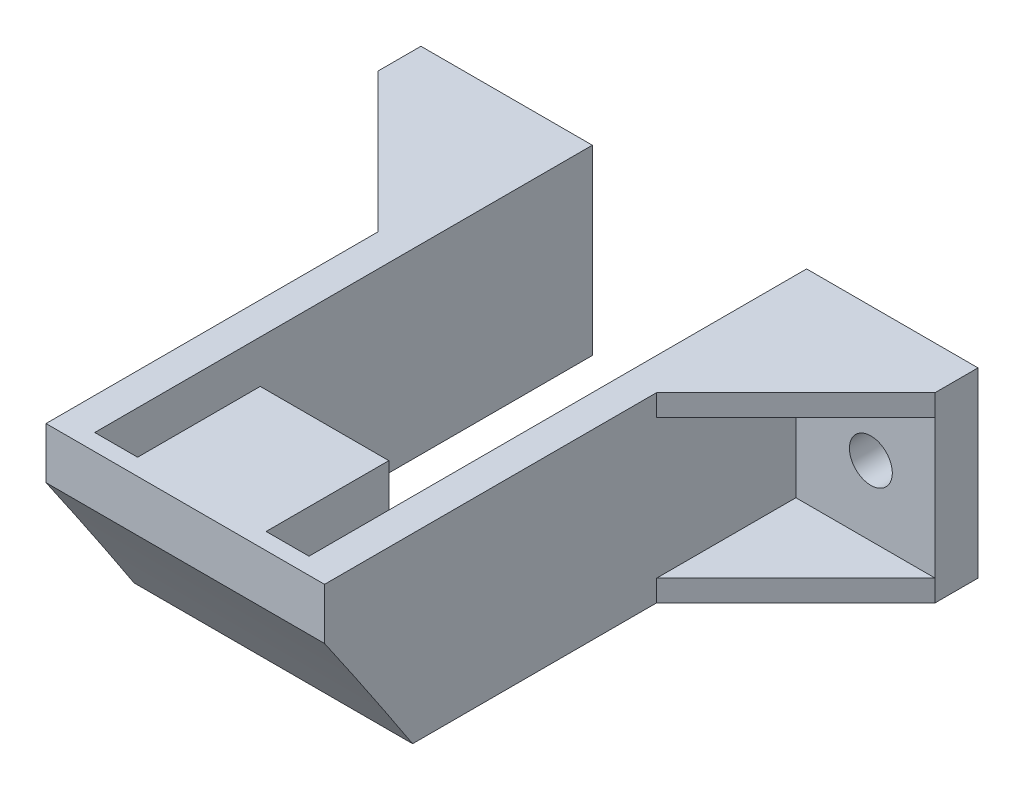
from build123d import *

# Parameters (mm, degrees)
BOSS_EXTRUDE1_DEPTH = 17
BOSS_EXTRUDE2_DEPTH = 2
BOSS_EXTRUDE3_DEPTH = 2
SKETCH6_R           = 2
CUT_EXTRUDE1_DEPTH  = 10
CUT_EXTRUDE2_DEPTH  = 4
CUT_EXTRUDE3_DEPTH  = 100
CUT_EXTRUDE4_DEPTH  = 4


with BuildPart() as part:
    # Sketch1 → Boss-Extrude1 (new body)
    with BuildSketch(Plane(origin=(0, 0, 0), x_dir=(1, 0, 0), z_dir=(0, 1, 0))):
        Polygon((-7.978390595, -3.663628582), (12.021609405, -3.663628582), (12.021609405, 31.336371418), (28.021609405, 31.336371418), (28.021609405, 27.336371418), (15.021609405, 27.336371418), (15.021609405, 18.231970095), (15.021609405, -16.663628582), (-10.978390595, -16.663628582), (-10.978390595, 22.152823879), (-10.978390595, 27.336371418), (-23.978390595, 27.336371418), (-23.978390595, 31.336371418), (-7.978390595, 31.336371418), align=None)
    extrude(amount=BOSS_EXTRUDE1_DEPTH)

    # Sketch4 → Boss-Extrude2 (add)
    with BuildSketch(Plane(origin=(0, 17, 0), x_dir=(1, 0, 0), z_dir=(0, 1, 0))):
        Polygon((-23.978390595, 27.336371418), (-10.978390595, 14.336371418), (-10.978390595, 27.336371418), align=None)
        Polygon((28.021609405, 27.336371418), (15.021609405, 14.336371418), (15.021609405, 27.336371418), align=None)
    extrude(amount=-BOSS_EXTRUDE2_DEPTH)

    # Sketch5 → Boss-Extrude3 (add)
    with BuildSketch(Plane.XZ):
        Polygon((-23.978390595, -27.336371418), (-10.978390595, -14.336371418), (-10.978390595, -27.336371418), align=None)
        Polygon((15.021609405, -14.336371418), (28.021609405, -27.336371418), (15.021609405, -27.336371418), align=None)
    extrude(amount=-BOSS_EXTRUDE3_DEPTH)

    # Sketch6 → Cut-Extrude1 (cut)
    with BuildSketch(Plane(origin=(0, 0, -31.336371418), x_dir=(-1, 0, 0), z_dir=(0, 0, -1))):
        with Locations((-22.021609405, 8.5)):
            Circle(SKETCH6_R)
        with Locations((17.978390595, 8.5)):
            Circle(SKETCH6_R)
    extrude(amount=-CUT_EXTRUDE1_DEPTH, mode=Mode.SUBTRACT)

    # Sketch7 → Cut-Extrude2 (cut)
    with BuildSketch(Plane(origin=(-7.978390595, 0, 0), x_dir=(0, 0, -1), z_dir=(1, 0, 0))):
        with BuildLine():
            Line((6.660260068, 17), (-15.113860184, 17))
            ThreePointArc((-15.113860184, 17), (-9.316147205, 8.548897323), (-3.663628582, 0))
            Line((-3.663628582, 0), (9.59929213, 0))
            Line((9.59929213, 0), (6.660260068, 17))
        make_face()
    extrude(amount=CUT_EXTRUDE2_DEPTH, mode=Mode.SUBTRACT)

    # Sketch8 → Cut-Extrude3 (cut)
    with BuildSketch(Plane.ZY.offset(10.978390595)):
        with BuildLine():
            Line((21.615286826, 19.275621448), (46.650832109, 12.975800719))
            Line((46.650832109, 12.975800719), (28.995853608, -26.911994427))
            Line((28.995853608, -26.911994427), (-0.690246805, -14.377221046))
            ThreePointArc((-0.690246805, -14.377221046), (10.177476822, 2.638130465), (21.615286826, 19.275621448))
        make_face()
    extrude(amount=-CUT_EXTRUDE3_DEPTH, mode=Mode.SUBTRACT)

    # Sketch9 → Cut-Extrude4 (cut)
    with BuildSketch(Plane.ZY.offset(-12.021609405)):
        with BuildLine():
            Line((-11.188223811, 17), (-11.188223811, 0))
            Line((-11.188223811, 0), (3.663628582, 0))
            ThreePointArc((3.663628582, 0), (9.316147205, 8.548897323), (15.113860184, 17))
            Line((15.113860184, 17), (-11.188223811, 17))
        make_face()
    extrude(amount=CUT_EXTRUDE4_DEPTH, mode=Mode.SUBTRACT)


solid = part.part
